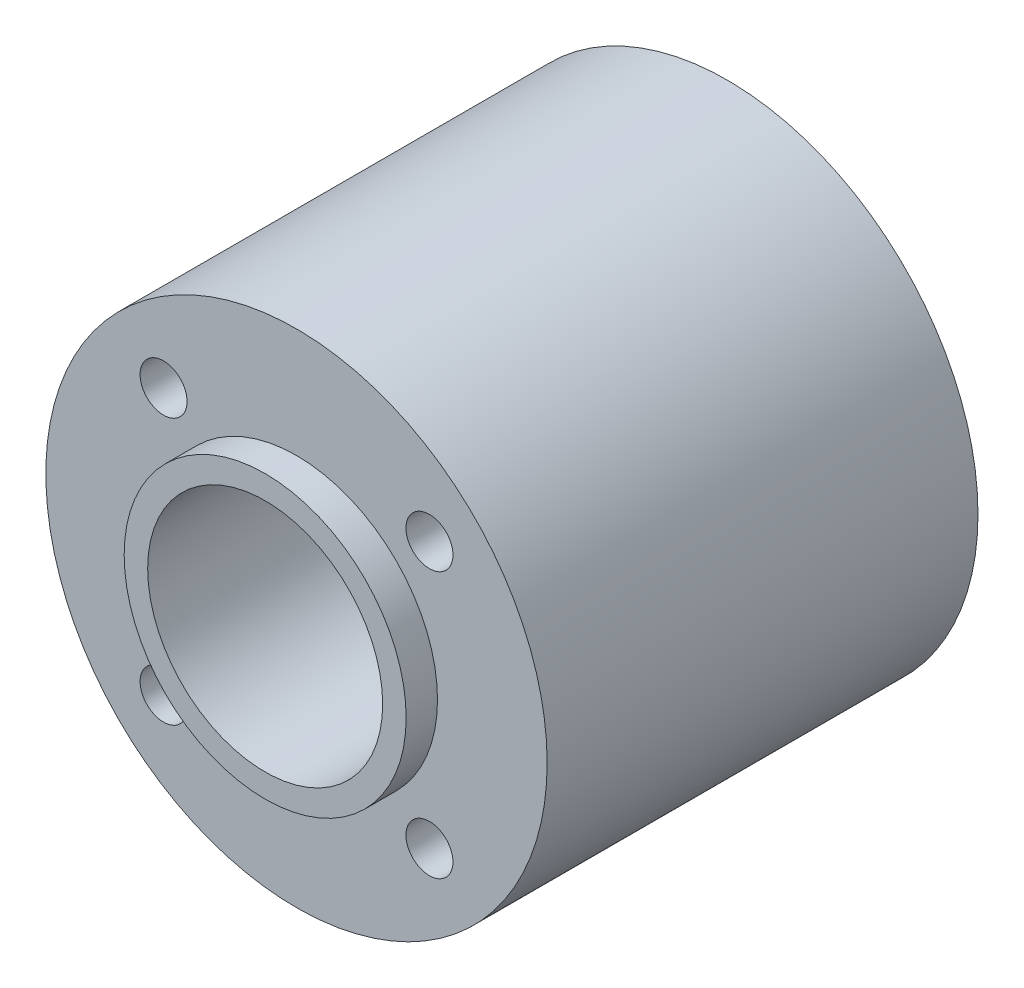
from build123d import *

# Parameters (mm, degrees)
SKETCH1_R           = 16
SKETCH1_R_2         = 9
SKETCH1_R_3         = 7.5
BOSS_EXTRUDE1_DEPTH = 27.5
SKETCH1_3_R         = 9
SKETCH1_3_R_2       = 7.5
BOSS_EXTRUDE2_DEPTH = 2
SKETCH3_R           = 1.5
CUT_EXTRUDE1_DEPTH  = 47
BOSS_EXTRUDE5_START = -27.5
SKETCH1_5_R         = 9
SKETCH1_5_R_2       = 7.5
BOSS_EXTRUDE5_DEPTH = 2
SCALE1_SCALE        = 1.667


with BuildPart() as part:
    # Sketch1 → Boss-Extrude1 (new body)
    with BuildSketch(Plane.XY):
        Circle(SKETCH1_R)
        Circle(SKETCH1_R_2, mode=Mode.SUBTRACT)
        Circle(SKETCH1_R_2)
        Circle(SKETCH1_R_3, mode=Mode.SUBTRACT)
    extrude(amount=-BOSS_EXTRUDE1_DEPTH)

    # Sketch1_3 → Boss-Extrude2 (add)
    with BuildSketch(Plane.XY):
        Circle(SKETCH1_3_R)
        Circle(SKETCH1_3_R_2, mode=Mode.SUBTRACT)
    extrude(amount=BOSS_EXTRUDE2_DEPTH)

    # Sketch3 → Cut-Extrude1 (cut)
    with BuildSketch(Plane.XY):
        with Locations((-8.485281374, 8.485281374)):
            Circle(SKETCH3_R)
        with Locations((8.485281374, 8.485281374)):
            Circle(SKETCH3_R)
        with Locations((8.485281374, -8.485281374)):
            Circle(SKETCH3_R)
        with Locations((-8.485281374, -8.485281374)):
            Circle(SKETCH3_R)
    extrude(amount=-CUT_EXTRUDE1_DEPTH, mode=Mode.SUBTRACT)

    # Sketch1_5 → Boss-Extrude5 (add)
    with BuildSketch(Plane.XY.offset(BOSS_EXTRUDE5_START)):
        Circle(SKETCH1_5_R)
        Circle(SKETCH1_5_R_2, mode=Mode.SUBTRACT)
    extrude(amount=-BOSS_EXTRUDE5_DEPTH)


with BuildPart() as part_1:
    # Scale1: scaled about (0, 0, -13.75)
    add(part.part.scale(SCALE1_SCALE).moved(Location((0, 0, 9.17125))))


solid = part_1.part
